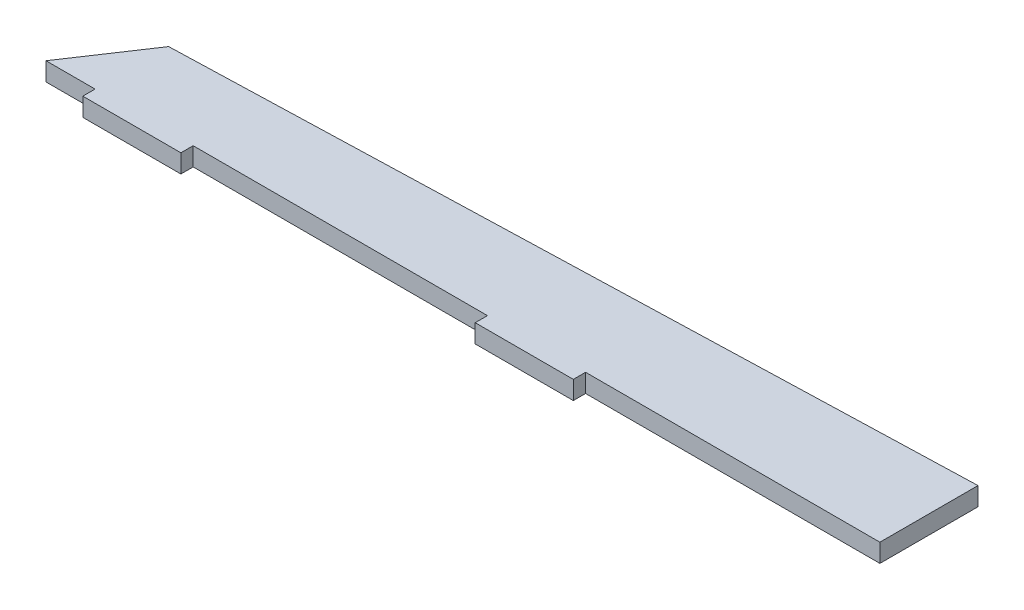
from build123d import *

# Parameters (mm, degrees)
BOSS_EXTRUDE1_DEPTH = 4.7625
SKETCH2_W           = 25.4
SKETCH2_H           = 3.175
BOSS_EXTRUDE2_DEPTH = 4.7625


with BuildPart() as part:
    # Sketch1 → Boss-Extrude1 (new body)
    with BuildSketch(Plane(origin=(0, 0, 0), x_dir=(1, 0, 0), z_dir=(0, 1, 0))):
        Polygon((0, 0), (-215.9, 0), (-203.2, 19.05), (0, 25.4), align=None)
    extrude(amount=BOSS_EXTRUDE1_DEPTH)

    # Sketch2 → Boss-Extrude2 (add)
    with BuildSketch(Plane(origin=(0, 4.7625, 0), x_dir=(1, 0, 0), z_dir=(0, 1, 0))):
        with Locations((-190.5, -1.5875)):
            Rectangle(SKETCH2_W, SKETCH2_H)
        with Locations((-88.9, -1.5875)):
            Rectangle(SKETCH2_W, SKETCH2_H)
    extrude(amount=-BOSS_EXTRUDE2_DEPTH)


solid = part.part
